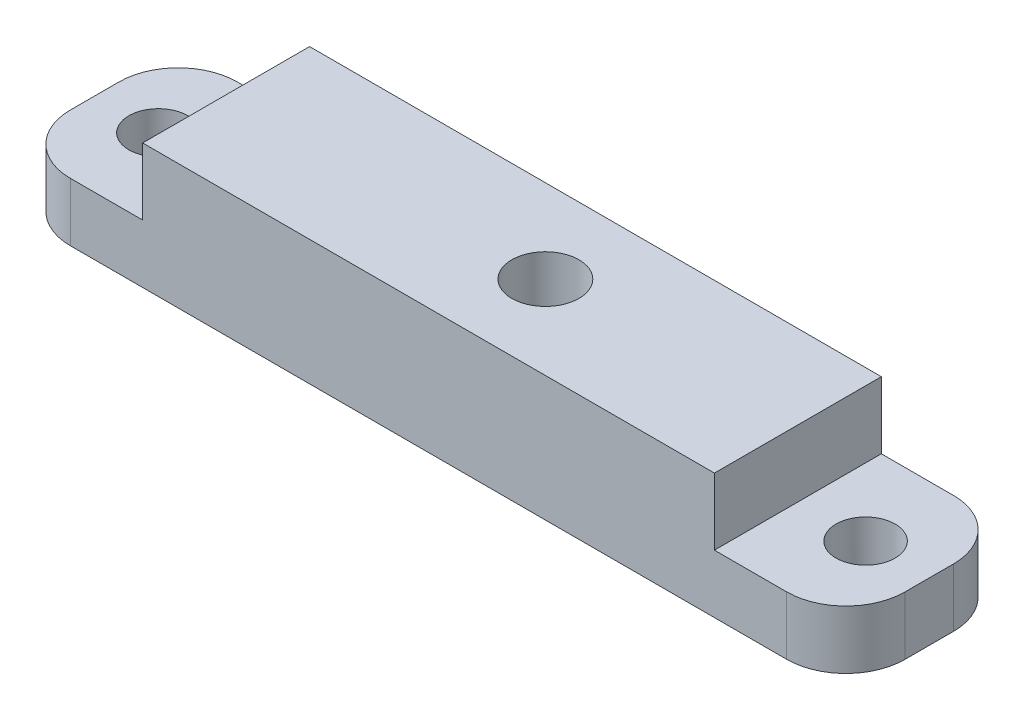
from build123d import *

# Parameters (mm, degrees)
SKETCH1_W               = 63.5
SKETCH1_H               = 12.7
EXTRUDE1_DEPTH          = 9.525
F_1_4_20_TAPPED_HOLE1_D = 5.1054
F_8_CLEARANCE_HOLE1_D   = 4.4958
SKETCH6_W               = 10
SKETCH6_H               = 12.7
CUT_EXTRUDE1_DEPTH      = 5.08
FILLET1_R               = 4.5


with BuildPart() as part:
    # Sketch1 → Extrude1 (new body)
    with BuildSketch(Plane(origin=(0, 0, 0), x_dir=(1, 0, 0), z_dir=(0, 1, 0))):
        Rectangle(SKETCH1_W, SKETCH1_H)
    extrude(amount=EXTRUDE1_DEPTH)

    # 1/4-20 Tapped Hole1 (through all)
    with Locations(Plane(origin=(-30.881531845, 9.525, 2.131635314), x_dir=(-1, 0, 0), z_dir=(0, 1, 0))):
        with Locations((-33.421531845, -2.131635314)):
            Hole(F_1_4_20_TAPPED_HOLE1_D / 2)

    # #8 Clearance Hole1 (through all)
    with Locations(Plane(origin=(34.21817196, 9.525, -1.204904774), x_dir=(-1, 0, 0), z_dir=(0, 1, 0))):
        with Locations((61.11817196, 1.204904774), (7.31817196, 1.204904774)):
            Hole(F_8_CLEARANCE_HOLE1_D / 2)

    # Sketch6 → Cut-Extrude1 (cut)
    with BuildSketch(Plane(origin=(0, 9.525, 0), x_dir=(-1, 0, 0), z_dir=(0, 1, 0))):
        with Locations((26.75, 0)):
            Rectangle(SKETCH6_W, SKETCH6_H)
        with Locations((-26.75, 0)):
            Rectangle(SKETCH6_W, SKETCH6_H)
    extrude(amount=-CUT_EXTRUDE1_DEPTH, mode=Mode.SUBTRACT)

    # Fillet1
    fillet1_edges = [part.edges().sort_by_distance(p)[0] for p in [
        (-31.75, 2.2225, -6.35),
        (-31.75, 2.2225, 6.35),
        (31.75, 2.2225, -6.35),
        (31.75, 2.2225, 6.35),
    ]]
    fillet(fillet1_edges, radius=FILLET1_R)


solid = part.part
